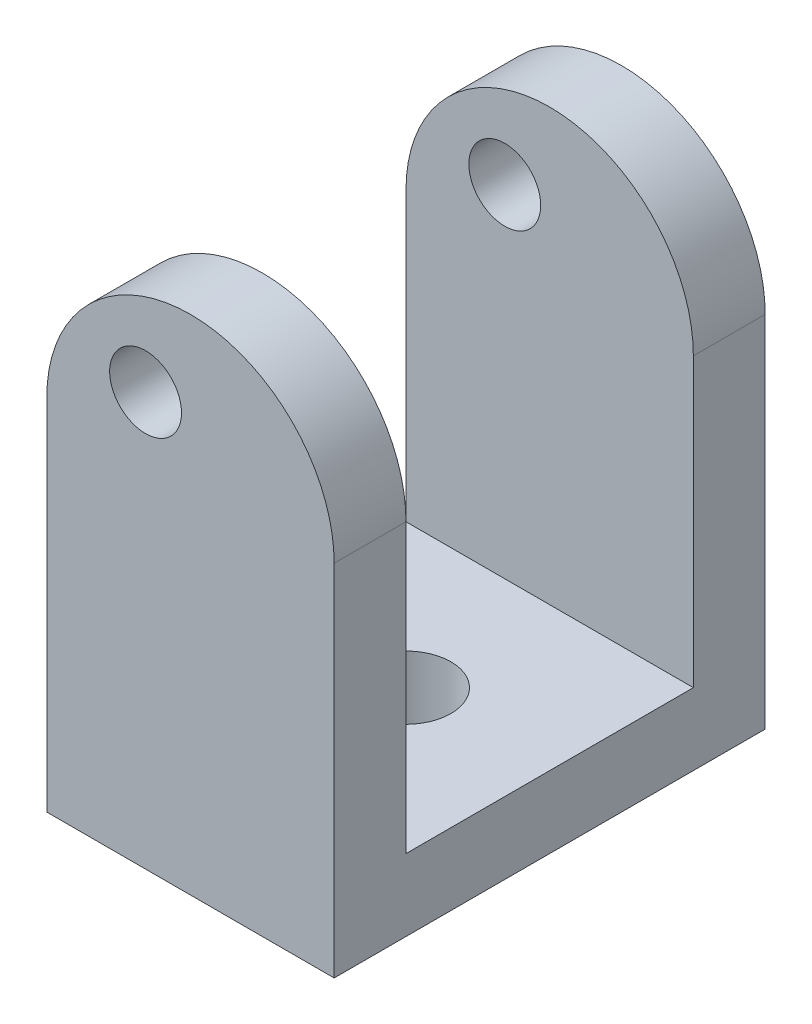
from build123d import *

# Parameters (mm, degrees)
SKETCH1_W           = 57.15
SKETCH1_H           = 38.1
BOSS_EXTRUDE1_DEPTH = 50.8
SKETCH4_W           = 25.4
SKETCH4_H           = 44.45
CUT_EXTRUDE2_DEPTH  = 79.801427652
SKETCH2_R           = 3.175
CUT_EXTRUDE1_DEPTH  = 70.633186233
SKETCH5_R           = 3.96875
CUT_EXTRUDE3_DEPTH  = 57.171484091


with BuildPart() as part:
    # Sketch1 → Boss-Extrude1 (new body)
    with BuildSketch(Plane(origin=(0, 0, 0), x_dir=(1, 0, 0), z_dir=(0, 1, 0))):
        Rectangle(SKETCH1_W, SKETCH1_H)
    extrude(amount=BOSS_EXTRUDE1_DEPTH)

    # Sketch4 → Cut-Extrude2 (cut, through all)
    with BuildSketch(Plane.ZY.offset(28.575)):
        with Locations((0, 28.575)):
            Rectangle(SKETCH4_W, SKETCH4_H)
    extrude(amount=-CUT_EXTRUDE2_DEPTH, mode=Mode.SUBTRACT)

    # Sketch2 → Cut-Extrude1 (cut, through all)
    with BuildSketch(Plane.XY.offset(19.05)):
        with BuildLine():
            Line((-3.175, 0), (28.575, 0))
            Line((28.575, 0), (28.575, 50.8))
            Line((28.575, 50.8), (-28.575, 50.8))
            Line((-28.575, 50.8), (-28.575, 31.75))
            ThreePointArc((-28.575, 31.75), (-15.875, 44.45), (-3.175, 31.75))
            Line((-3.175, 31.75), (-3.175, 0))
        make_face()
        with Locations((-19.84375, 36.5125)):
            Circle(SKETCH2_R)
    extrude(amount=-CUT_EXTRUDE1_DEPTH, mode=Mode.SUBTRACT)

    # Sketch5 → Cut-Extrude3 (cut, through all)
    with BuildSketch(Plane.XZ):
        with Locations(Location((-15.875, 0, 0), (0, 0, 270))):
            Circle(SKETCH5_R)
    extrude(amount=-CUT_EXTRUDE3_DEPTH, mode=Mode.SUBTRACT)


solid = part.part
